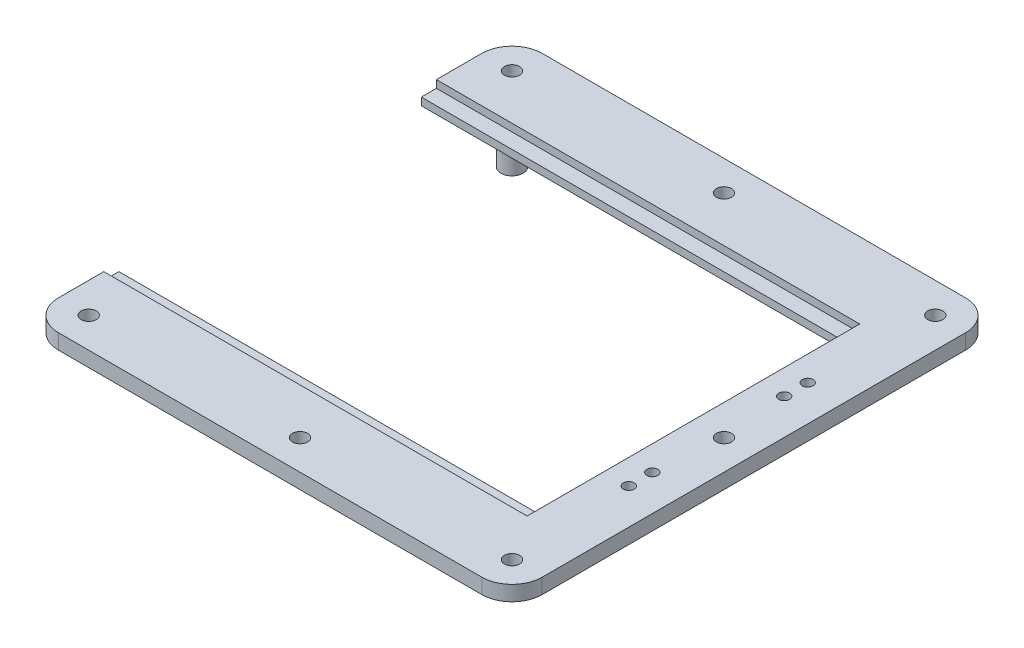
from build123d import *

# Parameters (mm, degrees)
BOSS_EXTRUDE2_DEPTH = 6.35
SKETCH2_R           = 3.175
CUT_EXTRUDE1_DEPTH  = 7.35
SKETCH5_R           = 4.6625
BOSS_EXTRUDE3_DEPTH = 12.7
SKETCH6_W           = 177.8
SKETCH6_H           = 6.35
CUT_EXTRUDE2_DEPTH  = 3.175
SKETCH7_R           = 2.286
CUT_EXTRUDE3_DEPTH  = 12.7
SKETCH8_R           = 3.175
CUT_EXTRUDE4_DEPTH  = 20.05


with BuildPart() as part:
    # Sketch1 → Boss-Extrude2 (new body)
    with BuildSketch(Plane(origin=(0, 0, 0), x_dir=(1, 0, 0), z_dir=(0, 1, 0))):
        with BuildLine():
            Line((0, 0), (0, 25.4))
            ThreePointArc((0, 25.4), (3.719743879, 34.380256121), (12.7, 38.1))
            Line((12.7, 38.1), (190.5, 38.1))
            ThreePointArc((190.5, 38.1), (199.480256121, 34.380256121), (203.2, 25.4))
            Line((203.2, 25.4), (203.2, -152.4))
            ThreePointArc((203.2, -152.4), (199.480256121, -161.380256121), (190.5, -165.1))
            Line((190.5, -165.1), (12.7, -165.1))
            ThreePointArc((12.7, -165.1), (3.719743879, -161.380256121), (0, -152.4))
            Line((0, -152.4), (0, -127))
            Line((0, -127), (177.8, -127))
            Line((177.8, -127), (177.8, 0))
            Line((177.8, 0), (0, 0))
        make_face()
    extrude(amount=BOSS_EXTRUDE2_DEPTH)

    # Sketch2 → Cut-Extrude1 (cut, through all)
    with BuildSketch(Plane(origin=(0, 6.35, 0), x_dir=(1, 0, 0), z_dir=(0, 1, 0))):
        with Locations((12.7, 25.4)):
            Circle(SKETCH2_R)
        with Locations((190.5, 25.4)):
            Circle(SKETCH2_R)
        with Locations((190.5, -152.4)):
            Circle(SKETCH2_R)
        with Locations((12.7, -152.4)):
            Circle(SKETCH2_R)
    extrude(amount=-CUT_EXTRUDE1_DEPTH, mode=Mode.SUBTRACT)

    # Sketch5 → Boss-Extrude3 (add)
    with BuildSketch(Plane.XZ):
        with Locations((28.575, 136.525)):
            Circle(SKETCH5_R)
        with Locations((174.625, 136.525)):
            Circle(SKETCH5_R)
        with Locations((174.625, -9.525)):
            Circle(SKETCH5_R)
        with Locations((28.575, -9.525)):
            Circle(SKETCH5_R)
    extrude(amount=BOSS_EXTRUDE3_DEPTH)

    # Sketch6 → Cut-Extrude2 (cut)
    with BuildSketch(Plane(origin=(0, 6.35, 0), x_dir=(1, 0, 0), z_dir=(0, 1, 0))):
        with Locations((88.9, -130.175)):
            Rectangle(SKETCH6_W, SKETCH6_H)
        with Locations((88.9, 3.175)):
            Rectangle(SKETCH6_W, SKETCH6_H)
    extrude(amount=-CUT_EXTRUDE2_DEPTH, mode=Mode.SUBTRACT)

    # Sketch7 → Cut-Extrude3 (cut)
    with BuildSketch(Plane(origin=(0, 6.35, 0), x_dir=(1, 0, 0), z_dir=(0, 1, 0))):
        with Locations((188.214, -101.092)):
            Circle(SKETCH7_R)
        with Locations((188.214, -91.186)):
            Circle(SKETCH7_R)
        with Locations((188.214, -35.814)):
            Circle(SKETCH7_R)
        with Locations((188.214, -25.908)):
            Circle(SKETCH7_R)
    extrude(amount=-CUT_EXTRUDE3_DEPTH, mode=Mode.SUBTRACT)

    # Sketch8 → Cut-Extrude4 (cut, through all)
    with BuildSketch(Plane(origin=(0, 6.35, 0), x_dir=(1, 0, 0), z_dir=(0, 1, 0))):
        with Locations((101.6, 25.527)):
            Circle(SKETCH8_R)
        with Locations((190.627, -63.5)):
            Circle(SKETCH8_R)
        with Locations((101.6, -152.527)):
            Circle(SKETCH8_R)
    extrude(amount=-CUT_EXTRUDE4_DEPTH, mode=Mode.SUBTRACT)


solid = part.part
